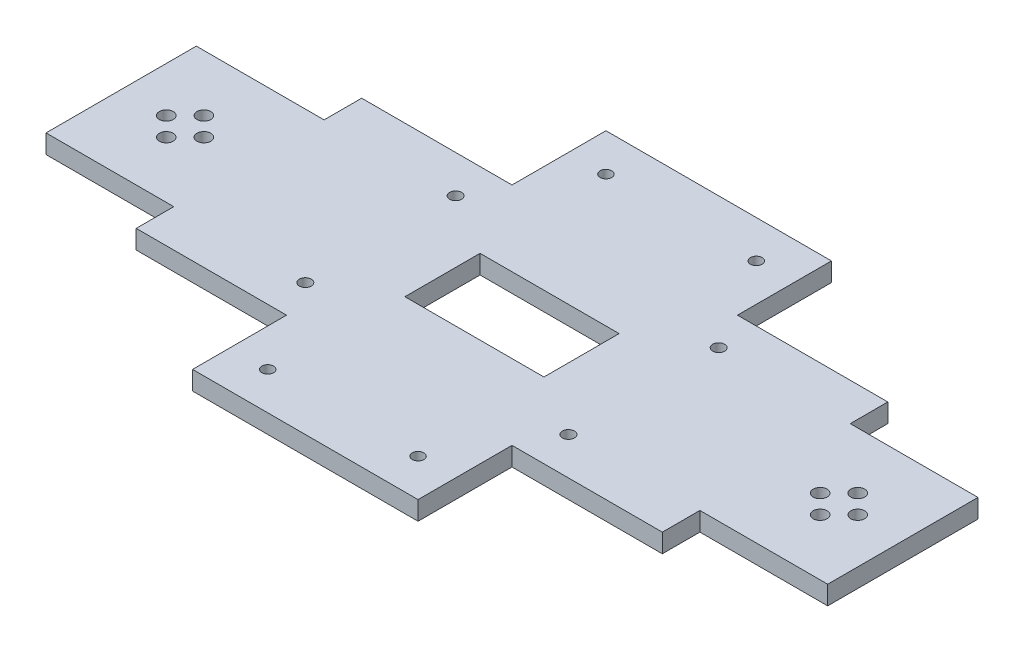
from build123d import *

# Parameters (mm, degrees)
SKETCH1_W           = 37
SKETCH1_H           = 20
SKETCH1_R           = 1.6
SKETCH1_R_2         = 1.85
BOSS_EXTRUDE1_DEPTH = 5
SKETCH2_W           = 60
SKETCH2_H           = 25
SKETCH2_R           = 1.55
BOSS_EXTRUDE2_DEPTH = 5


with BuildPart() as part:
    # Sketch1 → Boss-Extrude1 (new body)
    with BuildSketch(Plane(origin=(0, 0, 0), x_dir=(1, 0, 0), z_dir=(0, 1, 0))):
        Polygon((-70, 30), (-70, 20), (-104, 20), (-104, -20), (-70, -20), (-70, -30), (70, -30), (70, -20), (104, -20), (104, 20), (70, 20), (70, 30), align=None)
        Rectangle(SKETCH1_W, SKETCH1_H, mode=Mode.SUBTRACT)
        with Locations((-35, -20)):
            Circle(SKETCH1_R, mode=Mode.SUBTRACT)
        with Locations((-35, 20)):
            Circle(SKETCH1_R, mode=Mode.SUBTRACT)
        with Locations((35, -20)):
            Circle(SKETCH1_R, mode=Mode.SUBTRACT)
        with Locations((35, 20)):
            Circle(SKETCH1_R, mode=Mode.SUBTRACT)
        with Locations((-87, 5)):
            Circle(SKETCH1_R_2, mode=Mode.SUBTRACT)
        with Locations((-87, -5)):
            Circle(SKETCH1_R_2, mode=Mode.SUBTRACT)
        with Locations((-92, 0)):
            Circle(SKETCH1_R_2, mode=Mode.SUBTRACT)
        with Locations((-82, 0)):
            Circle(SKETCH1_R_2, mode=Mode.SUBTRACT)
        with Locations((87, 5)):
            Circle(SKETCH1_R_2, mode=Mode.SUBTRACT)
        with Locations((87, -5)):
            Circle(SKETCH1_R_2, mode=Mode.SUBTRACT)
        with Locations((82, 0)):
            Circle(SKETCH1_R_2, mode=Mode.SUBTRACT)
        with Locations((92, 0)):
            Circle(SKETCH1_R_2, mode=Mode.SUBTRACT)
    extrude(amount=BOSS_EXTRUDE1_DEPTH)

    # Sketch2 → Boss-Extrude2 (add)
    with BuildSketch(Plane(origin=(0, 5, 0), x_dir=(1, 0, 0), z_dir=(0, 1, 0))):
        with Locations((0, 42.5)):
            Rectangle(SKETCH2_W, SKETCH2_H)
        with Locations((20, 45)):
            Circle(SKETCH2_R, mode=Mode.SUBTRACT)
        with Locations((-20, 45)):
            Circle(SKETCH2_R, mode=Mode.SUBTRACT)
        with Locations((0, -42.5)):
            Rectangle(SKETCH2_W, SKETCH2_H)
        with Locations((20, -45)):
            Circle(SKETCH2_R, mode=Mode.SUBTRACT)
        with Locations((-20, -45)):
            Circle(SKETCH2_R, mode=Mode.SUBTRACT)
    extrude(amount=-BOSS_EXTRUDE2_DEPTH)


solid = part.part
